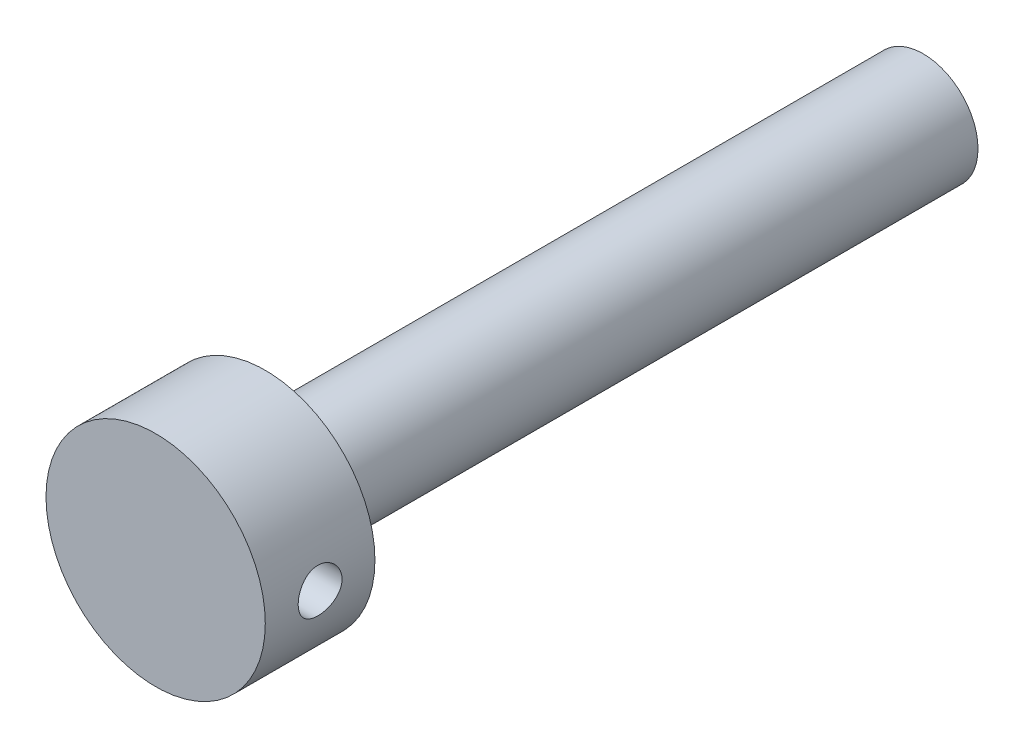
from build123d import *

# Parameters (mm, degrees)
SKETCH1_R               = 5
BOSS_EXTRUDE1_DEPTH     = 30
SKETCH3_R               = 10
BOSS_EXTRUDE3_DEPTH     = 10
SKETCH4_R               = 2
CUT_EXTRUDE1_DEPTH      = 11
CUT_EXTRUDE1_DEPTH_BACK = 11


with BuildPart() as part:
    # Sketch1 → Boss-Extrude1 (new body, symmetric)
    with BuildSketch(Plane.XY):
        Circle(SKETCH1_R)
    extrude(amount=BOSS_EXTRUDE1_DEPTH, both=True)

    # Sketch3 → Boss-Extrude3 (add)
    with BuildSketch(Plane.XY.offset(30)):
        Circle(SKETCH3_R)
    extrude(amount=BOSS_EXTRUDE3_DEPTH)

    # Sketch4 → Cut-Extrude1 (cut, two sides)
    with BuildSketch(Plane(origin=(0, 0, 0), x_dir=(0, 0, -1), z_dir=(1, 0, 0))) as cut_extrude1_sk:
        with Locations((-35, 0)):
            Circle(SKETCH4_R)
    extrude(amount=CUT_EXTRUDE1_DEPTH, mode=Mode.SUBTRACT)
    extrude(cut_extrude1_sk.sketch, amount=-CUT_EXTRUDE1_DEPTH_BACK, mode=Mode.SUBTRACT)


solid = part.part
